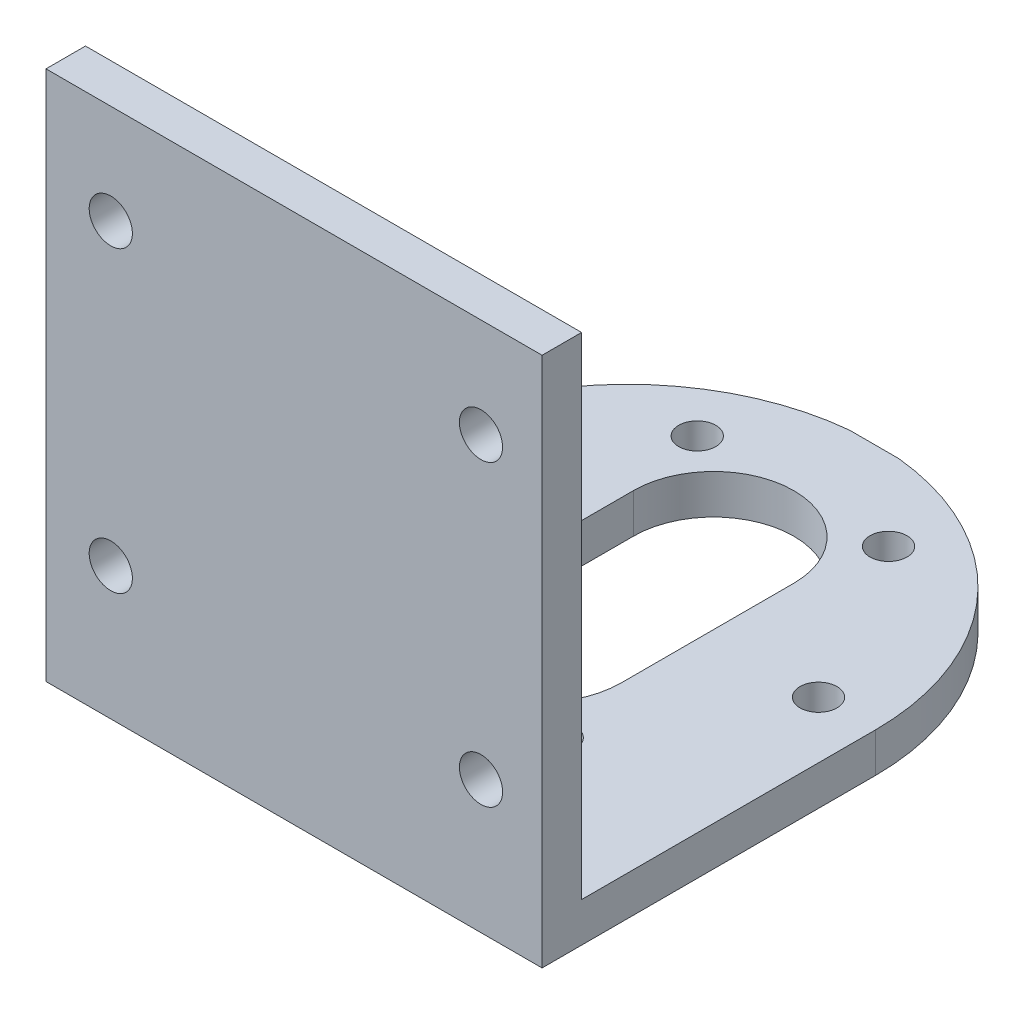
from build123d import *

# Parameters (mm, degrees)
SKETCH_1_W          = 40.2
SKETCH_1_H          = 39.8
SKETCH_1_R          = 1.75
SKETCH_1_H_2        = 3.2
EXTRUDE_1_DEPTH     = 3.2
SKETCH_2_W          = 40.2
SKETCH_2_H          = 3.2
EXTRUDE_2_DEPTH     = 43.8
SKETCH_3_R          = 1.5
CUT_EXTRUDE_1_DEPTH = 44
SKETCH_4_R          = 3.028542632
SKETCH_4_R_2        = 1.5
CUT_EXTRUDE_2_DEPTH = 1
CUT_EXTRUDE_3_DEPTH = 44


with BuildPart() as part:
    # 草图1 → 凸台-拉伸1 (new body)
    with BuildSketch(Plane.XY):
        with Locations((20.1, 23.1)):
            Rectangle(SKETCH_1_W, SKETCH_1_H)
        with Locations((5.25, 10.75)):
            Circle(SKETCH_1_R, mode=Mode.SUBTRACT)
        with Locations((35.25, 10.75)):
            Circle(SKETCH_1_R, mode=Mode.SUBTRACT)
        with Locations((5.25, 34.95)):
            Circle(SKETCH_1_R, mode=Mode.SUBTRACT)
        with Locations((35.25, 34.95)):
            Circle(SKETCH_1_R, mode=Mode.SUBTRACT)
        with Locations((20.1, 1.6)):
            Rectangle(SKETCH_1_W, SKETCH_1_H_2)
    extrude(amount=EXTRUDE_1_DEPTH)

    # 草图2 → 凸台-拉伸2 (add)
    with BuildSketch(Plane(origin=(0, 0, 0), x_dir=(-1, 0, 0), z_dir=(0, 0, -1))):
        with Locations((-20.1, 1.6)):
            Rectangle(SKETCH_2_W, SKETCH_2_H)
    extrude(amount=EXTRUDE_2_DEPTH)

    # 草图3 → 切除-拉伸1 (cut, through all)
    with BuildSketch(Plane.XZ):
        with BuildLine():
            Line((13.6, -23.8), (13.6, -30.8))
            ThreePointArc((13.6, -30.8), (20.1, -37.3), (26.6, -30.8))
            Line((26.6, -30.8), (26.6, -16.8))
            ThreePointArc((26.6, -16.8), (20.1, -10.3), (13.6, -16.8))
            Line((13.6, -16.8), (13.6, -23.8))
        make_face()
        with Locations((4.6, -23.8)):
            Circle(SKETCH_3_R)
        with Locations((12.35, -10.376606241)):
            Circle(SKETCH_3_R)
        with Locations((27.85, -10.376606241)):
            Circle(SKETCH_3_R)
        with Locations((35.6, -23.8)):
            Circle(SKETCH_3_R)
        with Locations((27.85, -37.223393759)):
            Circle(SKETCH_3_R)
        with Locations((12.35, -37.223393759)):
            Circle(SKETCH_3_R)
    extrude(amount=-CUT_EXTRUDE_1_DEPTH, mode=Mode.SUBTRACT)

    # 草图4 → 切除-拉伸2 (cut)
    with BuildSketch(Plane.XZ):
        with Locations((27.85, -37.223393759)):
            Circle(SKETCH_4_R)
        with Locations((27.85, -37.223393759)):
            Circle(SKETCH_4_R_2, mode=Mode.SUBTRACT)
        with Locations((12.35, -37.223393759)):
            Circle(SKETCH_4_R)
        with Locations((12.35, -37.223393759)):
            Circle(SKETCH_4_R_2, mode=Mode.SUBTRACT)
        with Locations((35.6, -23.8)):
            Circle(SKETCH_4_R)
        with Locations((35.6, -23.8)):
            Circle(SKETCH_4_R_2, mode=Mode.SUBTRACT)
        with Locations((27.85, -10.376606241)):
            Circle(SKETCH_4_R)
        with Locations((27.85, -10.376606241)):
            Circle(SKETCH_4_R_2, mode=Mode.SUBTRACT)
        with Locations((4.6, -23.8)):
            Circle(SKETCH_4_R)
        with Locations((12.35, -10.376606241)):
            Circle(SKETCH_4_R)
    extrude(amount=-CUT_EXTRUDE_2_DEPTH, mode=Mode.SUBTRACT)

    # 草图5 → 切除-拉伸3 (cut, through all)
    with BuildSketch(Plane.XZ):
        with BuildLine():
            ThreePointArc((18.097501561, -43.8), (5.195970031, -37.286285281), (0, -23.8))
            Line((0, -23.8), (0, -43.8))
            Line((0, -43.8), (18.097501561, -43.8))
        make_face()
        with BuildLine():
            Line((40.2, -43.8), (40.2, -23.8))
            ThreePointArc((40.2, -23.8), (35.004029969, -37.286285281), (22.102498439, -43.8))
            Line((22.102498439, -43.8), (40.2, -43.8))
        make_face()
    extrude(amount=-CUT_EXTRUDE_3_DEPTH, mode=Mode.SUBTRACT)


solid = part.part
